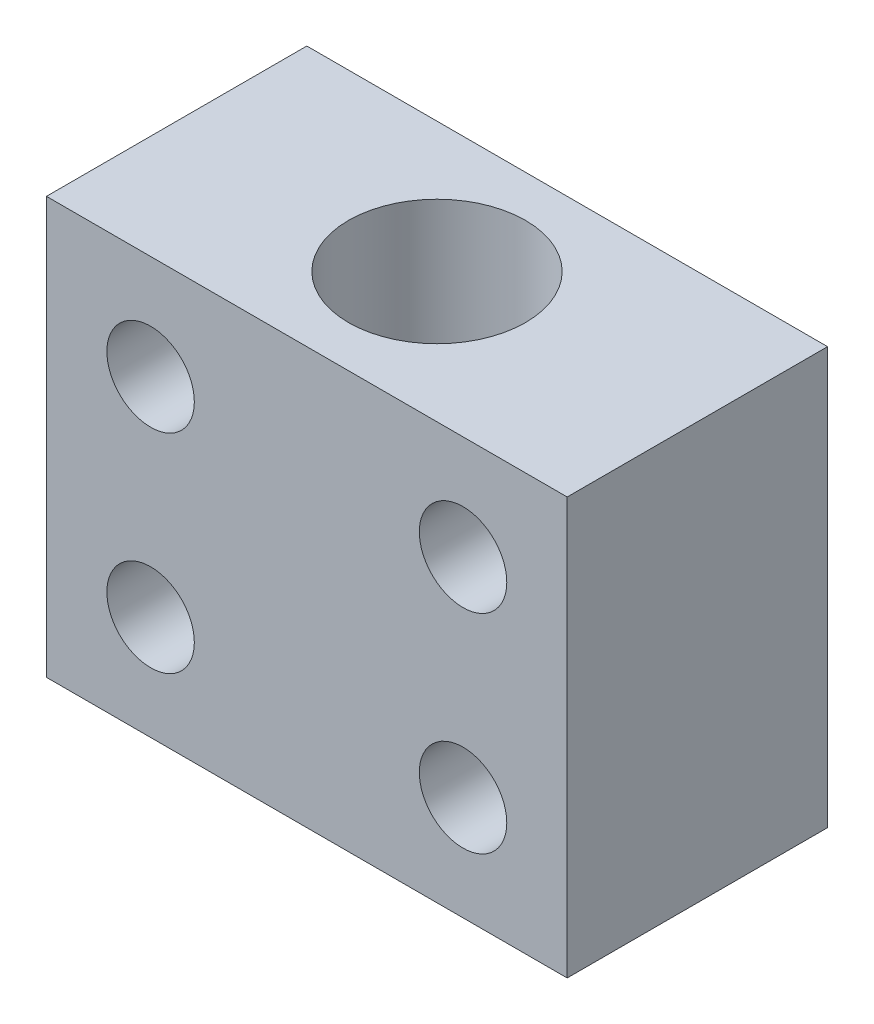
from build123d import *

# Parameters (mm, degrees)
CROQUIS1_W                    = 50
CROQUIS1_H                    = 40
SALIENTE_EXTRUIR1_DEPTH       = 12.5
TALADRO_DE_MARGEN_PARA_M81_D  = 8.4
TALADRO_DE_MARGEN_PARA_M161_D = 17


with BuildPart() as part:
    # Croquis1 → Saliente-Extruir1 (new body, symmetric)
    with BuildSketch(Plane.XY):
        Rectangle(CROQUIS1_W, CROQUIS1_H)
    extrude(amount=SALIENTE_EXTRUIR1_DEPTH, both=True)

    # Taladro de margen para M81 (through all)
    with Locations(Plane.XY.offset(12.5)):
        with Locations((-15, 10), (-15, -10), (15, -10), (15, 10)):
            Hole(TALADRO_DE_MARGEN_PARA_M81_D / 2)

    # Taladro de margen para M161 (through all)
    with Locations(Plane(origin=(0, 20, 0), x_dir=(1, 0, 0), z_dir=(0, 1, 0))):
        with Locations((0, 0)):
            Hole(TALADRO_DE_MARGEN_PARA_M161_D / 2)


solid = part.part
